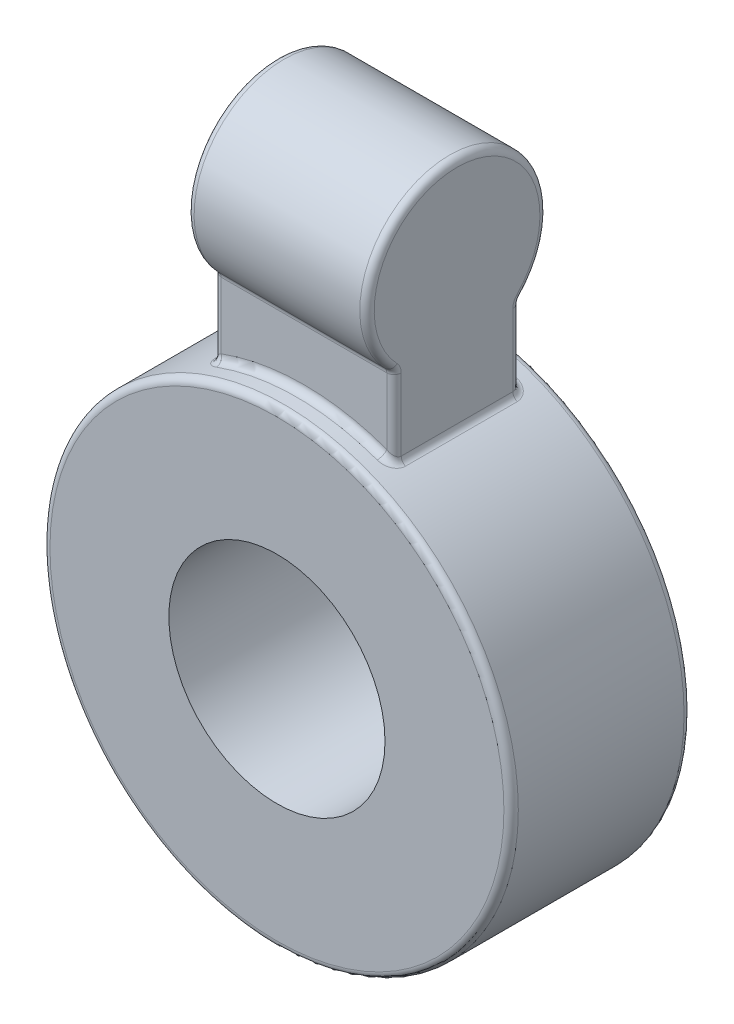
from build123d import *

# Parameters (mm, degrees)
ESQUISSE1_R      = 6.5
ESQUISSE1_R_2    = 3
EXTRUSION1_DEPTH = 2.5
ESQUISSE2_R      = 2.5
EXTRUSION2_DEPTH = 2.5
EXTRUSION3_DEPTH = 1.75
CONG_1_R         = 0.2


with BuildPart() as part:
    # Esquisse1 → Extrusion1 (new body, symmetric)
    with BuildSketch(Plane.XY):
        Circle(ESQUISSE1_R)
        Circle(ESQUISSE1_R_2, mode=Mode.SUBTRACT)
    extrude(amount=EXTRUSION1_DEPTH, both=True)



with BuildPart() as body_2:
    # Esquisse2 → Extrusion2 (new body, symmetric)
    with BuildSketch(Plane(origin=(0, 0, 0), x_dir=(0, 0, -1), z_dir=(1, 0, 0))):
        with Locations((0, 10)):
            Circle(ESQUISSE2_R)
    extrude(amount=EXTRUSION2_DEPTH, both=True)


with BuildPart() as part_1:
    add(part.part)

    add(body_2.part)  # Extrusion3 merges body 2
    # Esquisse3 → Extrusion3 (add, symmetric)
    with BuildSketch(Plane.XY):
        with BuildLine():
            Line((-2.5, 10), (2.5, 10))
            Line((2.5, 10), (2.5, 6))
            ThreePointArc((2.5, 6), (0, 6.5), (-2.5, 6))
            Line((-2.5, 6), (-2.5, 10))
        make_face()
    extrude(amount=EXTRUSION3_DEPTH, both=True)

    # Congé1
    cong_1_edges = [part_1.edges().sort_by_distance(p)[0] for p in [
        (0, 6.5, -1.75),
        (-2.5, 6, 0),
        (2.5, 7.107321446, -1.75),
        (2.5, 6, 0),
        (0, 6.5, 1.75),
        (2.5, 7.107321446, 1.75),
        (-6.5, 0, -2.5),
        (-2.5, 7.107321446, -1.75),
        (0, 8.214642893, -1.75),
        (-2.5, 7.107321446, 1.75),
        (0, 8.214642893, 1.75),
        (-2.5, 12.5, 0),
        (2.5, 12.5, 0),
        (-6.5, 0, 2.5),
    ]]
    fillet(cong_1_edges, radius=CONG_1_R)


solid = part_1.part
